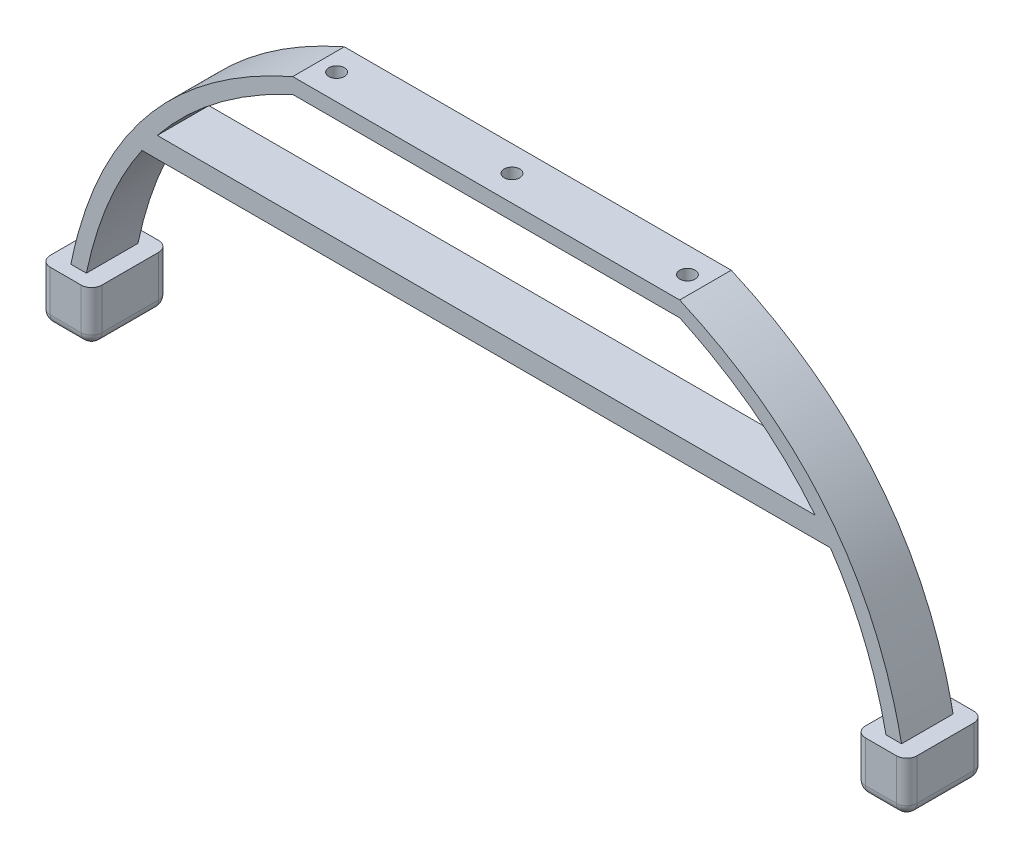
from build123d import *

# Parameters (mm, degrees)
BOSS_EXTRUDE1_DEPTH = 10
SKETCH2_R           = 1.5
CUT_EXTRUDE1_DEPTH  = 10
SKETCH3_W           = 10
SKETCH3_H           = 15
BOSS_EXTRUDE2_DEPTH = 10
FILLET1_R           = 2
FILLET2_R           = 2


with BuildPart() as part:
    # Sketch1 → Boss-Extrude1 (new body)
    with BuildSketch(Plane.XY):
        with BuildLine():
            Line((75, 0), (0, 0))
            add(Edge.make_bspline(
                [(0, 0), (-35.458503055, -15.603734429), (-43, -53)],
                knots=[0, 0, 0, 1, 1, 1], degree=2))
            Line((-43, -53), (-40, -53))
            add(Edge.make_bspline(
                [(-40, -53), (-36.902106975, -38.240903448), (-29.221449222, -27)],
                knots=[0, 0, 0, 0.424675214, 0.424675214, 0.424675214], degree=2))
            Line((-29.221449222, -27), (104.220036535, -27))
            add(Edge.make_bspline(
                [(104.220036535, -27), (111.901041982, -38.240979318), (115, -53)],
                knots=[1.077789281, 1.077789281, 1.077789281, 1.502471236, 1.502471236, 1.502471236], degree=2))
            Line((115, -53), (118, -53))
            add(Edge.make_bspline(
                [(118, -53), (110.458503055, -15.603734429), (75, 0)],
                knots=[0.536217864, 0.536217864, 0.536217864, 1.536217864, 1.536217864, 1.536217864], degree=2))
        make_face()
        with BuildLine():
            add(Edge.make_bspline(
                [(-26.253921627, -23), (-16.272049525, -10.585512223), (0, -3)],
                knots=[0.502463919, 0.502463919, 0.502463919, 1, 1, 1], degree=2))
            Line((0, -3), (75, -3))
            add(Edge.make_bspline(
                [(75, -3), (91.270620149, -10.585764027), (101.252432073, -23)],
                knots=[0.502471236, 0.502471236, 0.502471236, 1, 1, 1], degree=2))
            Line((101.252432073, -23), (-26.253921627, -23))
        make_face(mode=Mode.SUBTRACT)
    extrude(amount=BOSS_EXTRUDE1_DEPTH)

    # Sketch2 → Cut-Extrude1 (cut)
    with BuildSketch(Plane(origin=(0, 0, 0), x_dir=(1, 0, 0), z_dir=(0, 1, 0))):
        with Locations((71.5, -5)):
            Circle(SKETCH2_R)
        with Locations((3.5, -5)):
            Circle(SKETCH2_R)
        with Locations((37.5, -5)):
            Circle(SKETCH2_R)
    extrude(amount=-CUT_EXTRUDE1_DEPTH, mode=Mode.SUBTRACT)

    # Sketch3 → Boss-Extrude2 (add)
    with BuildSketch(Plane.XZ.offset(53)):
        with Locations((116.5, 5)):
            Rectangle(SKETCH3_W, SKETCH3_H)
        with Locations((-41.5, 5)):
            Rectangle(SKETCH3_W, SKETCH3_H)
    extrude(amount=BOSS_EXTRUDE2_DEPTH)

    # Fillet1
    fillet1_edges = [part.edges().sort_by_distance(p)[0] for p in [
        (111.5, -58, 12.5),
        (111.5, -58, -2.5),
        (121.5, -58, -2.5),
        (121.5, -58, 12.5),
        (111.5, -63, 5),
        (116.5, -63, -2.5),
        (121.5, -63, 5),
        (116.5, -63, 12.5),
    ]]
    fillet(fillet1_edges, radius=FILLET1_R)

    # Fillet2
    fillet2_edges = [part.edges().sort_by_distance(p)[0] for p in [
        (-36.5, -58, 12.5),
        (-46.5, -58, 12.5),
        (-46.5, -58, -2.5),
        (-36.5, -58, -2.5),
        (-41.5, -63, 12.5),
        (-46.5, -63, 5),
        (-41.5, -63, -2.5),
        (-36.5, -63, 5),
    ]]
    fillet(fillet2_edges, radius=FILLET2_R)


solid = part.part
